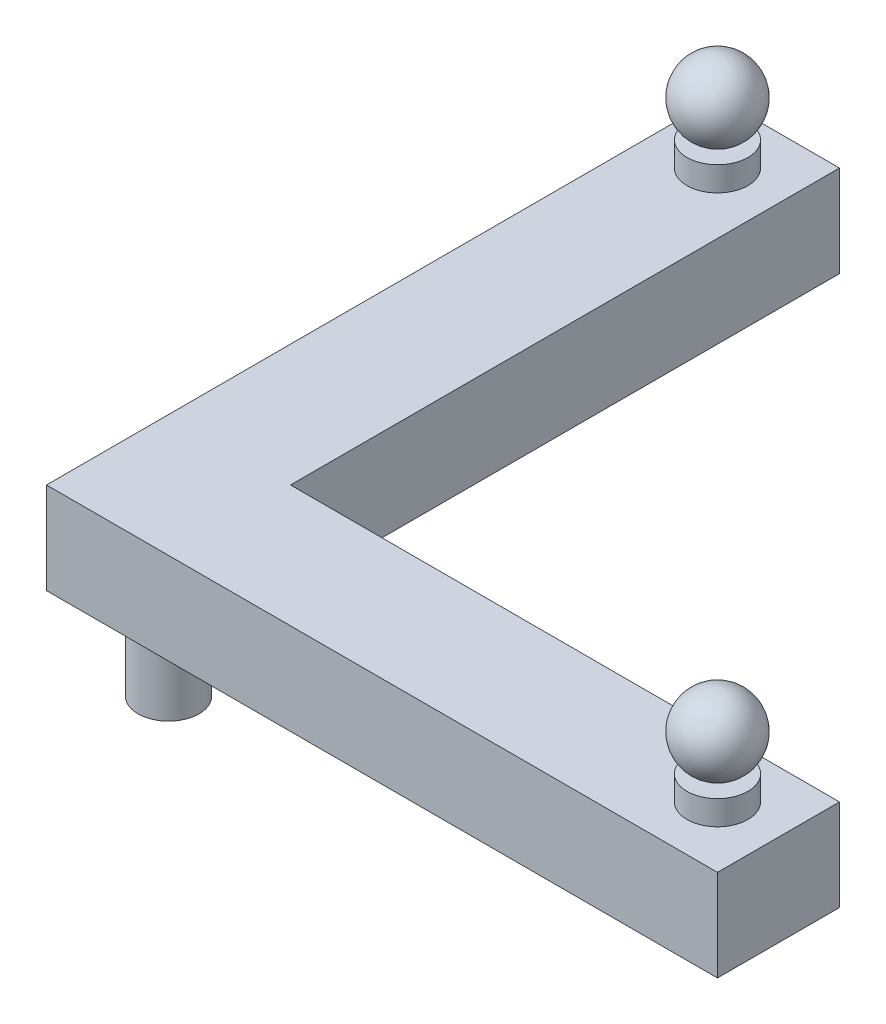
from build123d import *

# Parameters (mm, degrees)
BOSS_EXTRUDE1_DEPTH = 19.05
SKETCH3_R           = 6.35
BOSS_EXTRUDE2_DEPTH = 5.08
SKETCH4_R           = 6.35
BOSS_EXTRUDE3_DEPTH = 19.05


with BuildPart() as part:
    # Sketch2 → Boss-Extrude1 (new body)
    with BuildSketch(Plane(origin=(0, 0, 0), x_dir=(1, 0, 0), z_dir=(0, 1, 0))):
        Polygon((0, 139.7), (0, 0), (139.7, 0), (139.7, 25.4), (25.4, 25.4), (25.4, 139.7), align=None)
    extrude(amount=BOSS_EXTRUDE1_DEPTH)

    # Sketch3 → Boss-Extrude2 (add)
    with BuildSketch(Plane(origin=(0, 19.05, 0), x_dir=(1, 0, 0), z_dir=(0, 1, 0))):
        with Locations((127, 12.7)):
            Circle(SKETCH3_R)
        with Locations((12.7, 127)):
            Circle(SKETCH3_R)
    extrude(amount=BOSS_EXTRUDE2_DEPTH)

    # Sketch4 → Boss-Extrude3 (add)
    with BuildSketch(Plane.XZ):
        with Locations((12.7, -12.7)):
            Circle(SKETCH4_R)
    extrude(amount=BOSS_EXTRUDE3_DEPTH)


with BuildPart() as body_2:
    # Sketch5 → Revolve1 (revolve)
    with BuildSketch(Plane(origin=(0, 31.75, 0), x_dir=(1, 0, 0), z_dir=(0, 1, 0))):
        with BuildLine():
            Line((5.08, 127), (20.32, 127))
            ThreePointArc((20.32, 127), (12.7, 119.38), (5.08, 127))
        make_face()
    revolve(axis=Axis((5.08, 31.75, -127), (1, 0, 0)))


with BuildPart() as body_3:
    # Sketch6 → Revolve2 (revolve)
    with BuildSketch(Plane(origin=(0, 31.75, 0), x_dir=(1, 0, 0), z_dir=(0, 1, 0))):
        with BuildLine():
            Line((119.38, 12.7), (134.62, 12.7))
            ThreePointArc((134.62, 12.7), (127, 5.08), (119.38, 12.7))
        make_face()
    revolve(axis=Axis((119.38, 31.75, -12.7), (1, 0, 0)))


solid = Compound([part.part, body_2.part, body_3.part])
